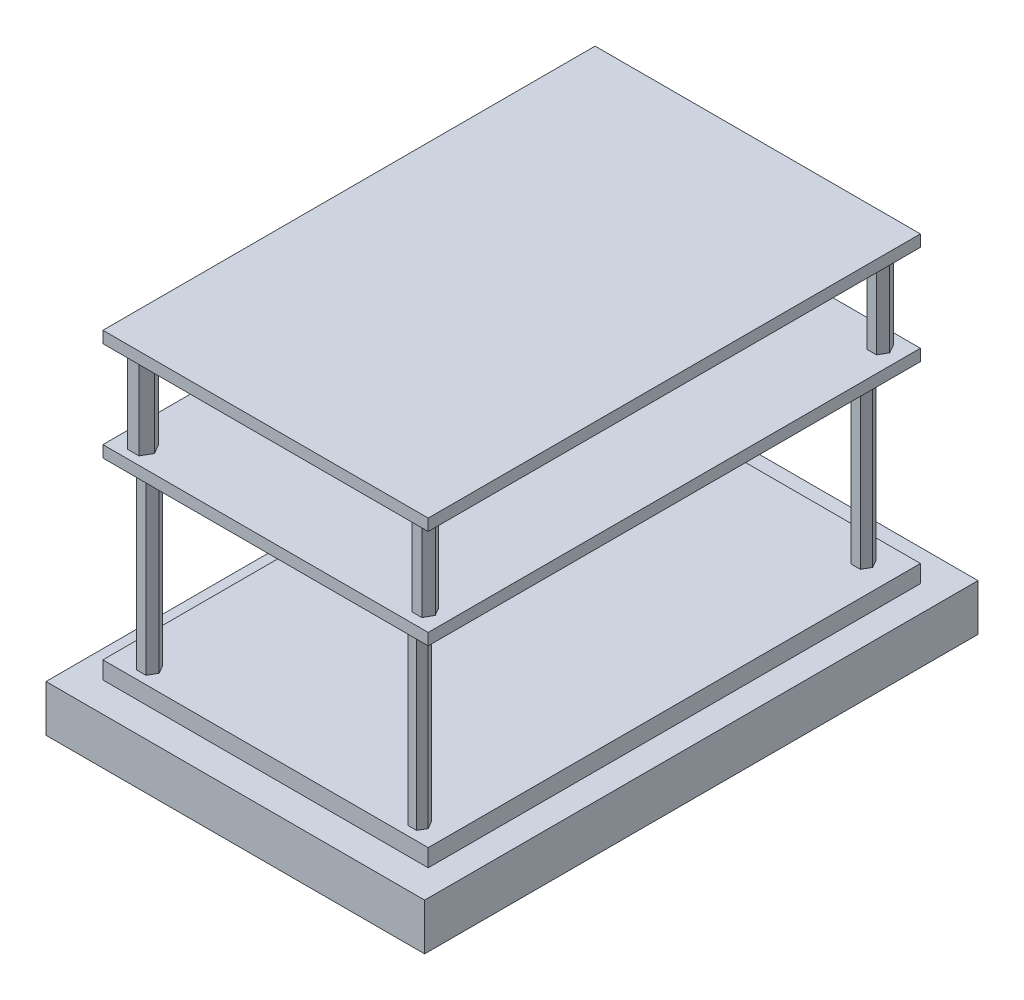
from build123d import *

# Parameters (mm, degrees)
SKETCH1_W           = 65
SKETCH1_H           = 95
BOSS_EXTRUDE1_DEPTH = 8
SKETCH2_W           = 55.842972677
SKETCH2_H           = 84.495387978
BOSS_EXTRUDE2_DEPTH = 3
BOSS_EXTRUDE3_DEPTH = 30
SKETCH4_W           = 55.842972677
SKETCH4_H           = 84.495387978
BOSS_EXTRUDE4_DEPTH = 2
BOSS_EXTRUDE5_DEPTH = 15
SKETCH6_W           = 55.842972677
SKETCH6_H           = 84.495387978
BOSS_EXTRUDE6_DEPTH = 2


with BuildPart() as part:
    # Sketch1 → Boss-Extrude1 (new body)
    with BuildSketch(Plane(origin=(0, 0, 0), x_dir=(1, 0, 0), z_dir=(0, 1, 0))):
        with Locations((-47.520746888, 4.139004149)):
            Rectangle(SKETCH1_W, SKETCH1_H)
    extrude(amount=BOSS_EXTRUDE1_DEPTH)

    # Sketch2 → Boss-Extrude2 (add)
    with BuildSketch(Plane(origin=(0, 8, 0), x_dir=(1, 0, 0), z_dir=(0, 1, 0))):
        with Locations((-47.434076541, 3.992818357)):
            Rectangle(SKETCH2_W, SKETCH2_H)
    extrude(amount=BOSS_EXTRUDE2_DEPTH)

    # Sketch3 → Boss-Extrude3 (add)
    with BuildSketch(Plane(origin=(0, 11, 0), x_dir=(1, 0, 0), z_dir=(0, 1, 0))):
        Polygon((-68.533559236, 41.562566991), (-69.361945393, 42.997373903), (-71.018717706, 42.997373903), (-71.847103863, 41.562566991), (-71.018717706, 40.127760079), (-69.361945393, 40.127760079), align=None)
        Polygon((-23.021049218, 41.562566991), (-23.800706777, 42.912973496), (-25.360021896, 42.912973496), (-26.139679455, 41.562566991), (-25.360021896, 40.212160486), (-23.800706777, 40.212160486), align=None)
        Polygon((-22.338848854, -35.42861698), (-23.069777816, -34.162610881), (-24.531635739, -34.162610881), (-25.262564701, -35.42861698), (-24.531635739, -36.694623078), (-23.069777816, -36.694623078), align=None)
        Polygon((-68.533559236, -35.42861698), (-69.361945393, -33.993810068), (-71.018717706, -33.993810068), (-71.847103863, -35.42861698), (-71.018717706, -36.863423892), (-69.361945393, -36.863423892), align=None)
    extrude(amount=BOSS_EXTRUDE3_DEPTH)

    # Sketch4 → Boss-Extrude4 (add)
    with BuildSketch(Plane(origin=(0, 41, 0), x_dir=(1, 0, 0), z_dir=(0, 1, 0))):
        with Locations((-47.434076541, 3.992818357)):
            Rectangle(SKETCH4_W, SKETCH4_H)
    extrude(amount=BOSS_EXTRUDE4_DEPTH)

    # Sketch5 → Boss-Extrude5 (add)
    with BuildSketch(Plane(origin=(0, 43, 0), x_dir=(1, 0, 0), z_dir=(0, 1, 0))):
        Polygon((-69.60558838, 42.92696772), (-70.580160329, 44.614975851), (-72.529304227, 44.614975851), (-73.503876176, 42.92696772), (-72.529304227, 41.238959588), (-70.580160329, 41.238959588), align=None)
        Polygon((-21.4617341, 42.92696772), (-22.290120256, 44.361774631), (-23.94689257, 44.361774631), (-24.775278726, 42.92696772), (-23.94689257, 41.492160808), (-22.290120256, 41.492160808), align=None)
        Polygon((-22.290120256, -33.666923337), (-23.976783563, -33.68418091), (-24.80516972, -35.153502968), (-23.94689257, -36.605567453), (-22.260229263, -36.58830988), (-21.431843106, -35.118987822), align=None)
        Polygon((-69.60558838, -35.153502968), (-70.580160329, -33.465494837), (-72.529304227, -33.465494837), (-73.503876176, -35.153502968), (-72.529304227, -36.8415111), (-70.580160329, -36.8415111), align=None)
    extrude(amount=BOSS_EXTRUDE5_DEPTH)

    # Sketch6 → Boss-Extrude6 (add)
    with BuildSketch(Plane(origin=(0, 58, 0), x_dir=(1, 0, 0), z_dir=(0, 1, 0))):
        with Locations((-47.434076541, 3.992818357)):
            Rectangle(SKETCH6_W, SKETCH6_H)
    extrude(amount=BOSS_EXTRUDE6_DEPTH)


solid = part.part
